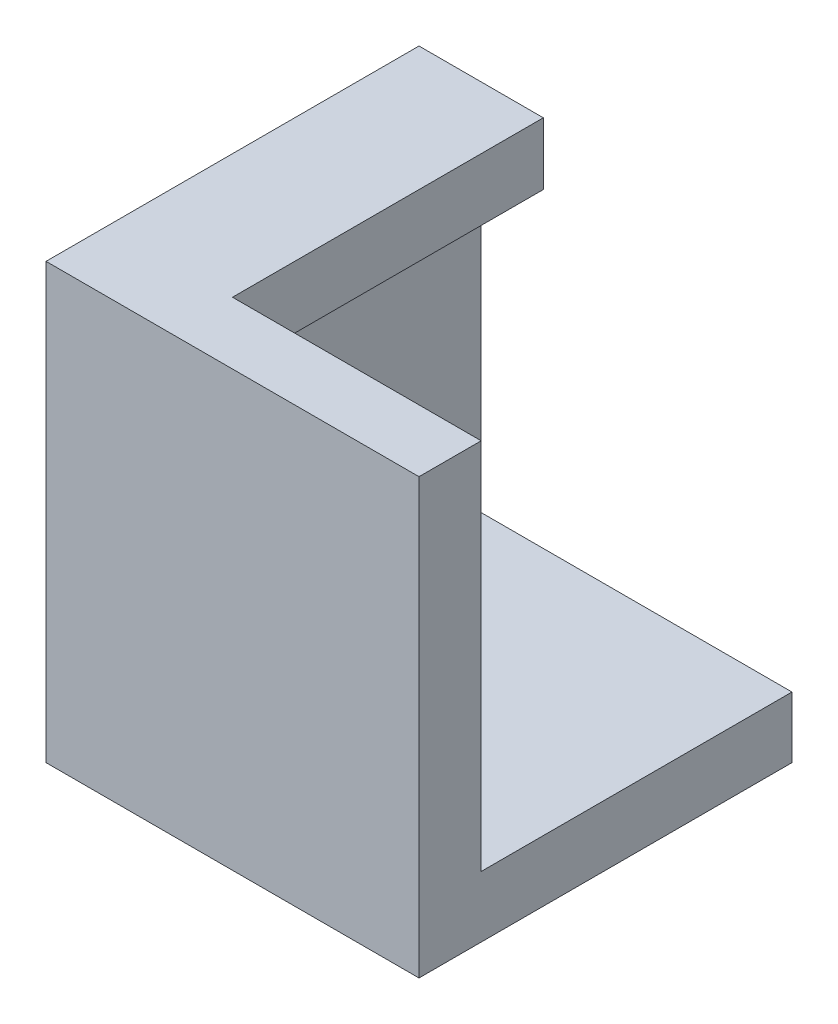
from build123d import *

# Parameters (mm, degrees)
SKETCH1_W           = 60.96
SKETCH1_H           = 60.96
BOSS_EXTRUDE1_DEPTH = 10
BOSS_EXTRUDE2_DEPTH = 60.96
SKETCH5_W           = 50.8
SKETCH5_H           = 10.16
BOSS_EXTRUDE3_DEPTH = 10.16
SKETCH6_R           = 6.35
CUT_EXTRUDE1_DEPTH  = 8.89


with BuildPart() as part:
    # Sketch1 → Boss-Extrude1 (new body)
    with BuildSketch(Plane(origin=(0, 0, 0), x_dir=(1, 0, 0), z_dir=(0, 1, 0))):
        with Locations((30.48, 30.48)):
            Rectangle(SKETCH1_W, SKETCH1_H)
    extrude(amount=BOSS_EXTRUDE1_DEPTH)

    # Sketch2 → Boss-Extrude2 (add)
    with BuildSketch(Plane(origin=(0, 10, 0), x_dir=(1, 0, 0), z_dir=(0, 1, 0))):
        Polygon((0, 60.96), (10.16, 60.96), (10.16, 10.16), (60.96, 10.16), (60.96, 0), (0, 0), align=None)
    extrude(amount=BOSS_EXTRUDE2_DEPTH)

    # Sketch5 → Boss-Extrude3 (add)
    with BuildSketch(Plane(origin=(10.16, 0, 0), x_dir=(0, 0, -1), z_dir=(1, 0, 0))):
        with Locations((35.56, 65.88)):
            Rectangle(SKETCH5_W, SKETCH5_H)
    extrude(amount=BOSS_EXTRUDE3_DEPTH)

    # Sketch6 → Cut-Extrude1 (cut)
    with BuildSketch(Plane.XZ):
        with Locations((30.48, -30.48)):
            Circle(SKETCH6_R)
    extrude(amount=-CUT_EXTRUDE1_DEPTH, mode=Mode.SUBTRACT)


solid = part.part
